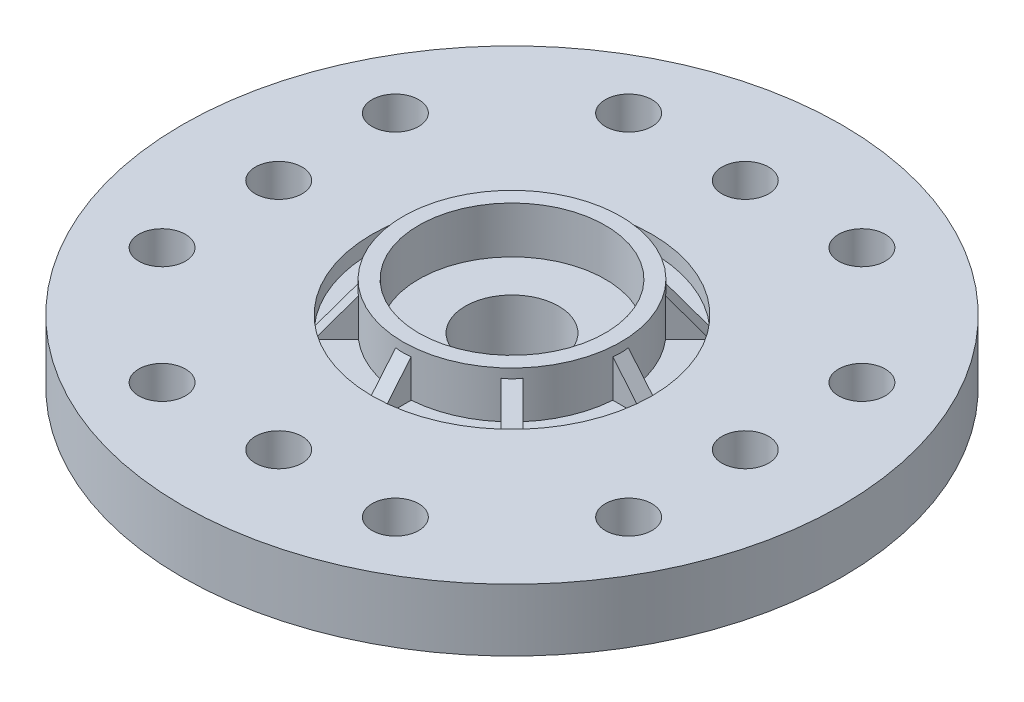
from build123d import *

# Parameters (mm, degrees)
SKETCH1_R           = 10.6
BOSS_EXTRUDE1_DEPTH = 2
SKETCH2_R           = 0.75
CUT_EXTRUDE2_DEPTH  = 3
CIRPATTERN1_COUNT   = 4
SKETCH3_R           = 3.85
BOSS_EXTRUDE2_DEPTH = 4.5
SKETCH4_R           = 3
CUT_EXTRUDE3_DEPTH  = 3.5
SKETCH5_R           = 1.5
CUT_EXTRUDE4_DEPTH  = 4
FILLET1_R           = 1
SKETCH6_R           = 4.5
CUT_EXTRUDE5_DEPTH  = 0.5
SKETCH7_R           = 3.5
SKETCH7_R_2         = 3
BOSS_EXTRUDE3_DEPTH = 1.5
BOSS_EXTRUDE4_DEPTH = 0.25
CIRPATTERN2_COUNT   = 8


with BuildPart() as part:
    # Sketch1 → Boss-Extrude1 (new body)
    with BuildSketch(Plane(origin=(0, 0, 0), x_dir=(1, 0, 0), z_dir=(0, 1, 0))):
        Circle(SKETCH1_R)
    extrude(amount=BOSS_EXTRUDE1_DEPTH)

    # Sketch2 → Cut-Extrude2 (cut, through all)
    with BuildSketch(Plane(origin=(0, 0, 0), x_dir=(1, 0, 0), z_dir=(0, 1, 0))):
        with Locations((-3.75, 7.5)):
            Circle(SKETCH2_R)
        with Locations((3.75, 7.5)):
            Circle(SKETCH2_R)
        with Locations((0, 7.5)):
            Circle(SKETCH2_R)
    cut_extrude2 = extrude(amount=CUT_EXTRUDE2_DEPTH, mode=Mode.SUBTRACT)

    # CirPattern1: Cut-Extrude2 ×4 about axis
    cirpattern1_axis = Axis((0, 0, 0), (0, 1, 0))
    for i in range(1, CIRPATTERN1_COUNT):
        add(cut_extrude2.rotate(cirpattern1_axis, i * 360 / CIRPATTERN1_COUNT), mode=Mode.SUBTRACT)

    # Sketch3 → Boss-Extrude2 (add)
    with BuildSketch(Plane.XZ):
        Circle(SKETCH3_R)
    extrude(amount=BOSS_EXTRUDE2_DEPTH)

    # Sketch4 → Cut-Extrude3 (cut)
    with BuildSketch(Plane.XZ.offset(4.5)):
        Circle(SKETCH4_R)
    extrude(amount=-CUT_EXTRUDE3_DEPTH, mode=Mode.SUBTRACT)

    # Sketch5 → Cut-Extrude4 (cut, through all)
    with BuildSketch(Plane.XZ.offset(1)):
        Circle(SKETCH5_R)
    extrude(amount=-CUT_EXTRUDE4_DEPTH, mode=Mode.SUBTRACT)

    # Fillet1
    fillet1_edges = [part.edges().sort_by_distance(p)[0] for p in [
        (-3.85, 0, 0),
    ]]
    fillet(fillet1_edges, radius=FILLET1_R)

    # Sketch6 → Cut-Extrude5 (cut)
    with BuildSketch(Plane(origin=(0, 2, 0), x_dir=(1, 0, 0), z_dir=(0, 1, 0))):
        Circle(SKETCH6_R)
    extrude(amount=-CUT_EXTRUDE5_DEPTH, mode=Mode.SUBTRACT)

    # Sketch7 → Boss-Extrude3 (add)
    with BuildSketch(Plane(origin=(0, 1.5, 0), x_dir=(1, 0, 0), z_dir=(0, 1, 0))):
        Circle(SKETCH7_R)
        Circle(SKETCH7_R_2, mode=Mode.SUBTRACT)
    extrude(amount=BOSS_EXTRUDE3_DEPTH)

    # Sketch8 → Boss-Extrude4 (add, symmetric)
    with BuildSketch(Plane(origin=(0, 0, 0), x_dir=(0, 0, -1), z_dir=(1, 0, 0))):
        Polygon((-4.5, 1.5), (-3, 1.5), (-3, 3), (-3.25, 3), align=None)
    boss_extrude4 = extrude(amount=BOSS_EXTRUDE4_DEPTH, both=True)

    # CirPattern2: Boss-Extrude4 ×8 about axis
    cirpattern2_axis = Axis((0, 0, 0), (0, 1, 0))
    for i in range(1, CIRPATTERN2_COUNT):
        add(boss_extrude4.rotate(cirpattern2_axis, i * 360 / CIRPATTERN2_COUNT))


solid = part.part
